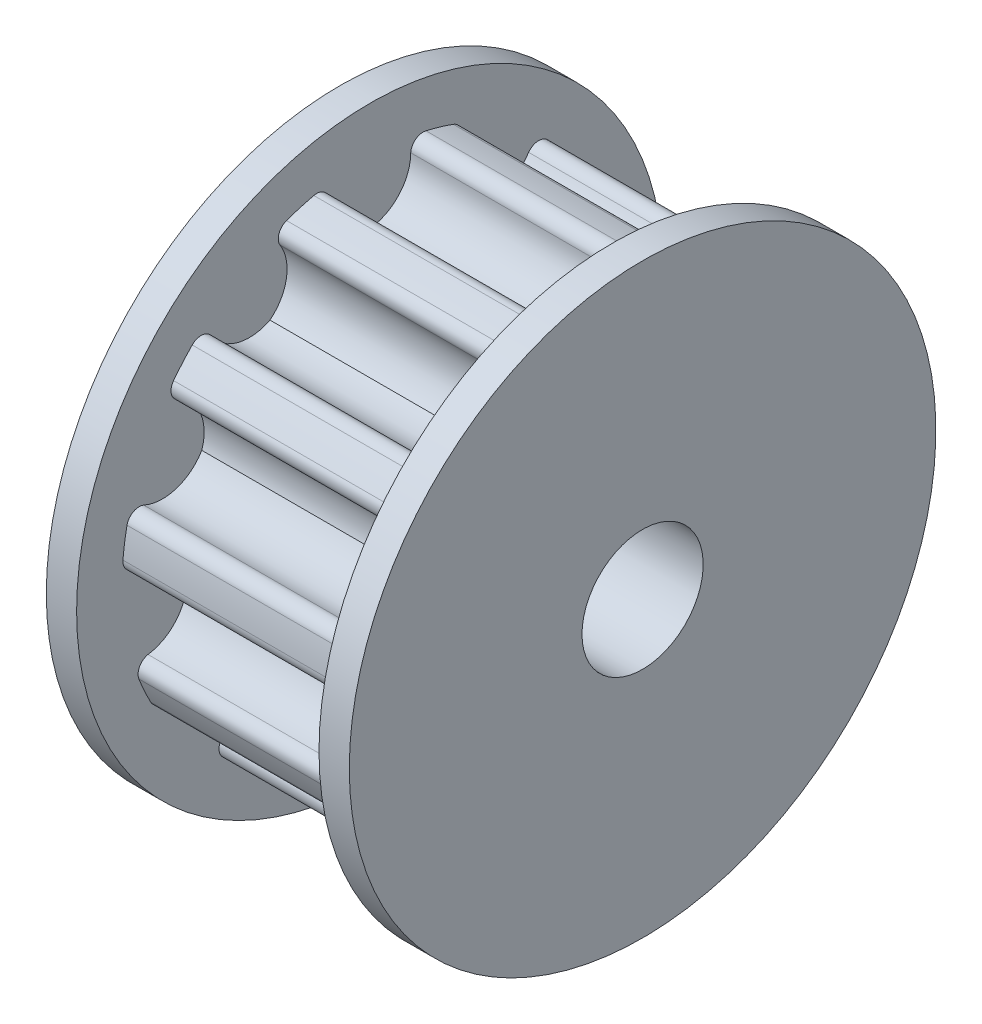
from build123d import *

# Parameters (mm, degrees)
SKETCH1_R           = 8.18
BOSS_EXTRUDE1_DEPTH = 8
CUT_EXTRUDE1_DEPTH  = 9
CIRPATTERN1_COUNT   = 11
SKETCH4_R           = 9.68
BOSS_EXTRUDE2_DEPTH = 1
SKETCH6_R           = 2
CUT_EXTRUDE2_DEPTH  = 11


with BuildPart() as part:
    # Sketch1 → Boss-Extrude1 (new body)
    with BuildSketch(Plane(origin=(0, 0, 0), x_dir=(0, 0, -1), z_dir=(1, 0, 0))):
        Circle(SKETCH1_R)
    extrude(amount=BOSS_EXTRUDE1_DEPTH)

    # Sketch2 → Cut-Extrude1 (cut, through all)
    with BuildSketch(Plane(origin=(0, 0, 0), x_dir=(0, 0, -1), z_dir=(1, 0, 0))):
        with BuildLine():
            ThreePointArc((0, 6.1), (0.961072859, 6.586806473), (1.347953386, 7.592274046))
            ThreePointArc((1.347953386, 7.592274046), (1.511589464, 7.896914613), (1.85, 7.96805497))
            ThreePointArc((1.85, 7.96805497), (0, 8.18), (-1.85, 7.96805497))
            ThreePointArc((-1.85, 7.96805497), (-1.511589464, 7.896914613), (-1.347953386, 7.592274046))
            ThreePointArc((-1.347953386, 7.592274046), (-0.961072859, 6.586806473), (0, 6.1))
        make_face()
    cut_extrude1 = extrude(amount=CUT_EXTRUDE1_DEPTH, mode=Mode.SUBTRACT)

    # CirPattern1: Cut-Extrude1 ×11 about axis
    cirpattern1_axis = Axis((0, 0, 0), (1, 0, 0))
    for i in range(1, CIRPATTERN1_COUNT):
        add(cut_extrude1.rotate(cirpattern1_axis, i * 360 / CIRPATTERN1_COUNT), mode=Mode.SUBTRACT)

    # Sketch4 → Boss-Extrude2 (add)
    with BuildSketch(Plane.ZY):
        Circle(SKETCH4_R)
    boss_extrude2 = extrude(amount=BOSS_EXTRUDE2_DEPTH)

    # Mirror1: Boss-Extrude2 across plane
    add(boss_extrude2.mirror(Plane.ZY.offset(-4)))

    # Sketch6 → Cut-Extrude2 (cut, through all)
    with BuildSketch(Plane.ZY.offset(1)):
        Circle(SKETCH6_R)
    extrude(amount=-CUT_EXTRUDE2_DEPTH, mode=Mode.SUBTRACT)


solid = part.part
